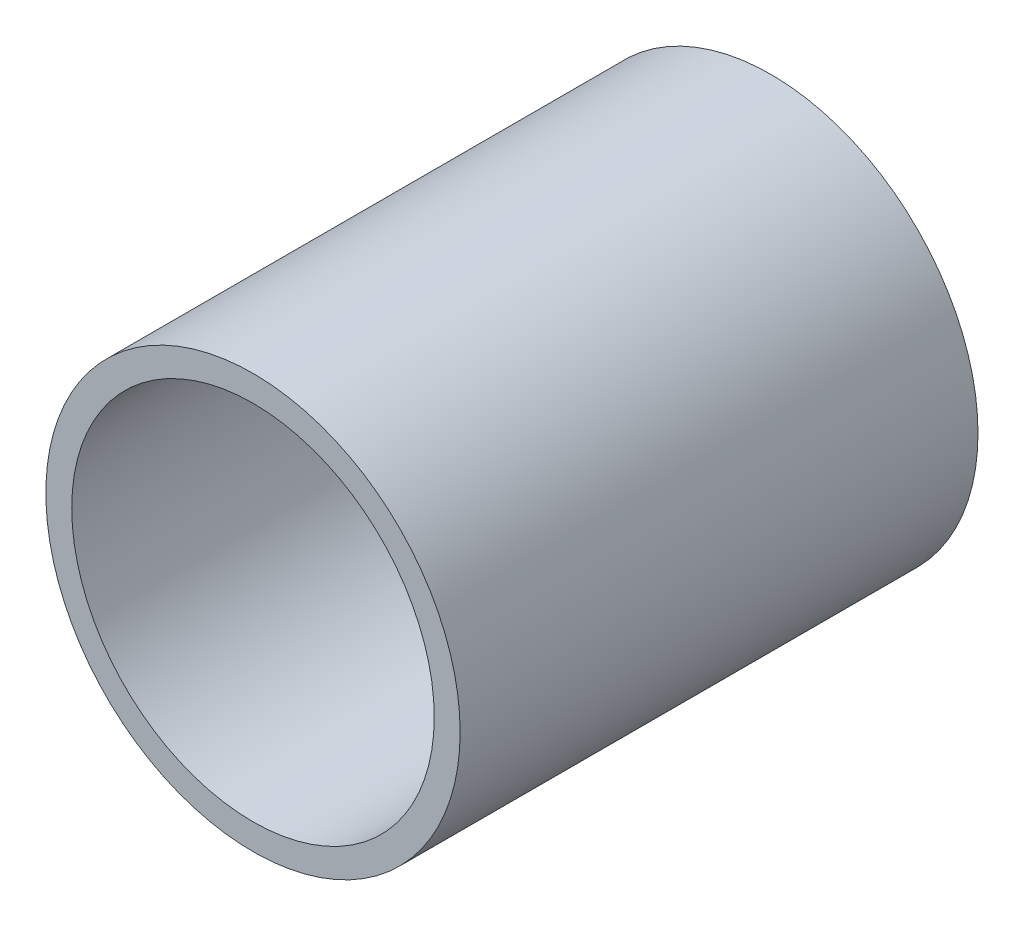
from build123d import *

# Parameters (mm, degrees)
SKETCH_1_R          = 16
EXTRUDE_1_DEPTH     = 40
SKETCH_2_R          = 14
CUT_EXTRUDE_1_DEPTH = 41


with BuildPart() as part:
    # Эскиз1 → Бобышка-Вытянуть1 (new body)
    with BuildSketch(Plane.XY):
        Circle(SKETCH_1_R)
    extrude(amount=EXTRUDE_1_DEPTH)

    # Эскиз2 → Вырез-Вытянуть1 (cut, through all)
    with BuildSketch(Plane(origin=(0, 0, 0), x_dir=(-1, 0, 0), z_dir=(0, 0, -1))):
        Circle(SKETCH_2_R)
    extrude(amount=-CUT_EXTRUDE_1_DEPTH, mode=Mode.SUBTRACT)


solid = part.part
